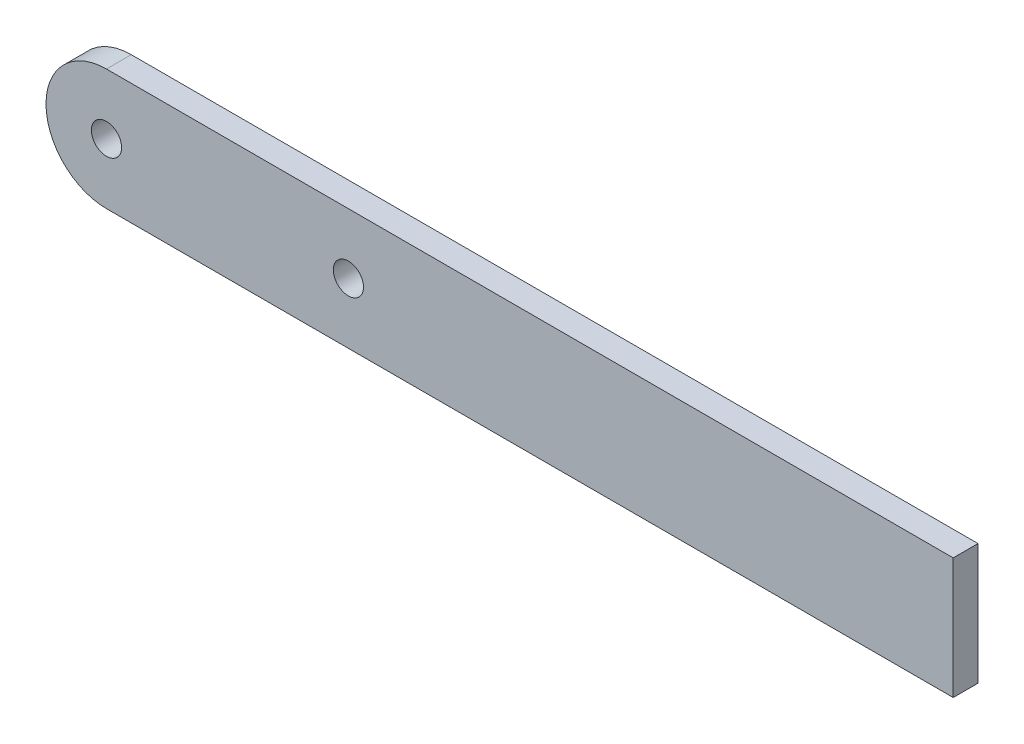
from build123d import *

# Parameters (mm, degrees)
SKETCH2_R           = 3.175
BOSS_EXTRUDE2_DEPTH = 5.207


with BuildPart() as part:
    # Sketch2 → Boss-Extrude2 (new body)
    with BuildSketch(Plane.XY):
        with BuildLine():
            Line((0, 0), (177.8, 0))
            Line((177.8, 0), (177.8, 25.4))
            Line((177.8, 25.4), (0, 25.4))
            ThreePointArc((0, 25.4), (-12.7, 12.7), (0, 0))
        make_face()
        with Locations((0, 12.7)):
            Circle(SKETCH2_R, mode=Mode.SUBTRACT)
        with Locations((50.8, 12.7)):
            Circle(SKETCH2_R, mode=Mode.SUBTRACT)
    extrude(amount=BOSS_EXTRUDE2_DEPTH)


solid = part.part
